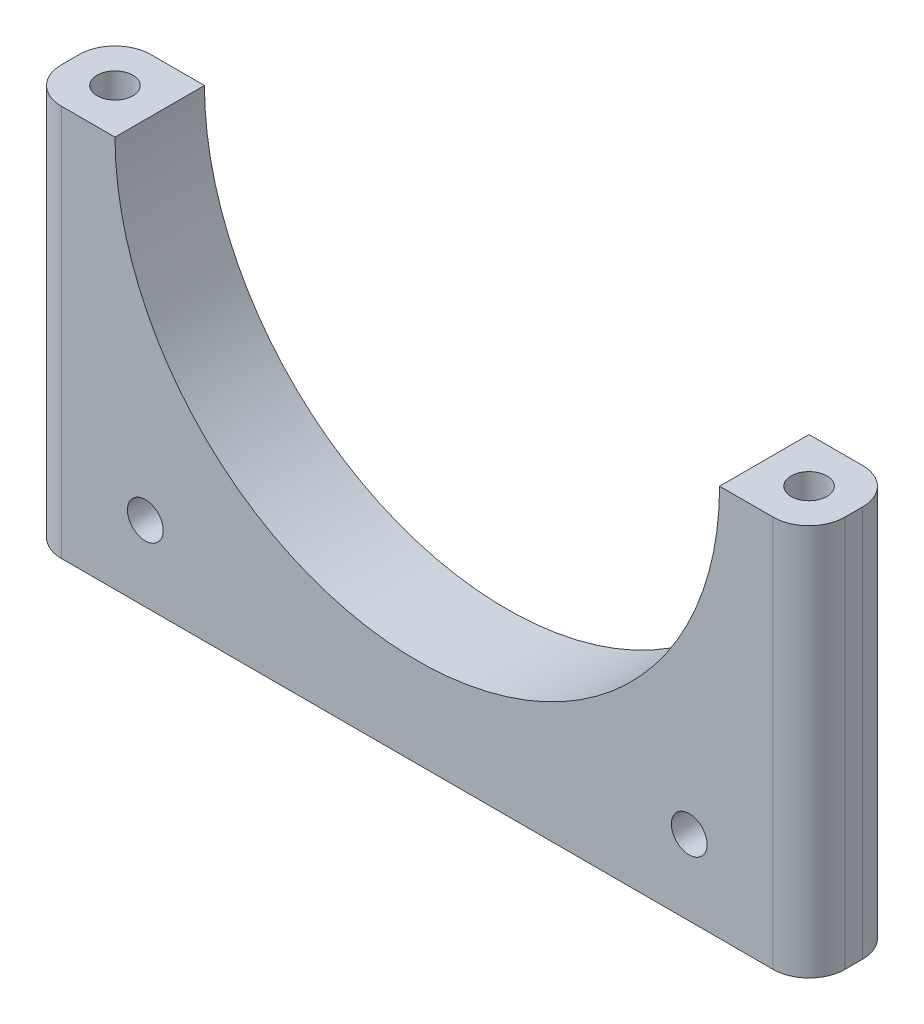
from build123d import *

# Parameters (mm, degrees)
BOSS_EXTRUDE1_DEPTH = 25
SKETCH5_R           = 5
CUT_EXTRUDE1_DEPTH  = 5000
SKETCH6_R           = 5
CUT_EXTRUDE2_DEPTH  = 5000
FILLET2_R           = 10


with BuildPart() as part:
    # Sketch4 → Boss-Extrude1 (new body)
    with BuildSketch(Plane.XY):
        with BuildLine():
            ThreePointArc((0, -25), (-77.42819254, 7.07180746), (-109.5, 84.5))
            Line((-109.5, 84.5), (-109.5, -25))
            Line((-109.5, -25), (0, -25))
        make_face()
        with BuildLine():
            ThreePointArc((84.5, 84.5), (59.75052301, 24.74947699), (0, 0))
            ThreePointArc((0, 0), (-59.75052301, 24.74947699), (-84.5, 84.5))
            Line((-84.5, 84.5), (-109.5, 84.5))
            ThreePointArc((-109.5, 84.5), (-77.42819254, 7.07180746), (0, -25))
            ThreePointArc((0, -25), (77.42819254, 7.07180746), (109.5, 84.5))
            Line((109.5, 84.5), (84.5, 84.5))
        make_face()
        with BuildLine():
            Line((109.5, -25), (109.5, 84.5))
            ThreePointArc((109.5, 84.5), (77.42819254, 7.07180746), (0, -25))
            Line((0, -25), (109.5, -25))
        make_face()
    extrude(amount=BOSS_EXTRUDE1_DEPTH)

    # Sketch5 → Cut-Extrude1 (cut)
    with BuildSketch(Plane(origin=(0, 84.5, 0), x_dir=(1, 0, 0), z_dir=(0, 1, 0))):
        with Locations((-97, -12.5)):
            Circle(SKETCH5_R)
        with Locations((97, -12.5)):
            Circle(SKETCH5_R)
    extrude(amount=-CUT_EXTRUDE1_DEPTH, mode=Mode.SUBTRACT)

    # Sketch6 → Cut-Extrude2 (cut)
    with BuildSketch(Plane.XY.offset(25)):
        with Locations((-76.015, -4)):
            Circle(SKETCH6_R)
        with Locations((76.015, -4)):
            Circle(SKETCH6_R)
    extrude(amount=-CUT_EXTRUDE2_DEPTH, mode=Mode.SUBTRACT)

    # Fillet2
    fillet2_edges = [part.edges().sort_by_distance(p)[0] for p in [
        (109.5, 29.75, 25),
        (-109.5, 29.75, 25),
        (-109.5, 29.75, 0),
        (109.5, 29.75, 0),
    ]]
    fillet(fillet2_edges, radius=FILLET2_R)


solid = part.part
